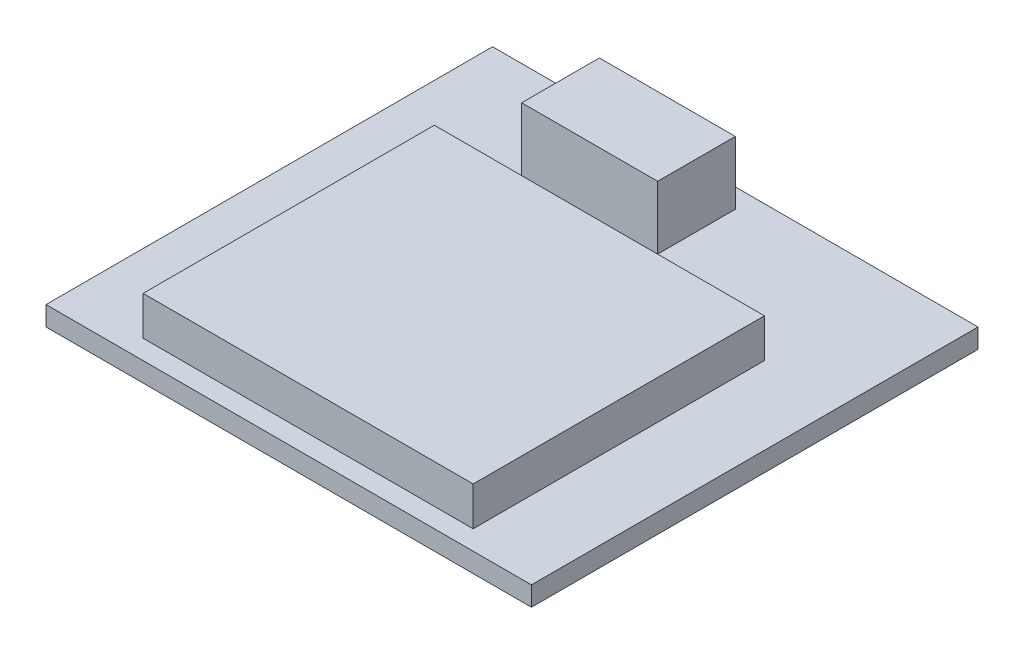
from build123d import *

# Parameters (mm, degrees)
SKETCH1_W           = 25
SKETCH1_H           = 23
BOSS_EXTRUDE1_DEPTH = 1
SKETCH2_W           = 17
SKETCH2_H           = 15
BOSS_EXTRUDE2_DEPTH = 2
SKETCH3_W           = 7
SKETCH3_H           = 4
BOSS_EXTRUDE3_DEPTH = 3.25
SKETCH4_W           = 15
SKETCH4_H           = 17
BOSS_EXTRUDE4_DEPTH = 0.75
SKETCH5_W           = 12.45
SKETCH5_H           = 0.6
CUT_EXTRUDE1_DEPTH  = 16.75
SKETCH6_R           = 0.770478249
CUT_EXTRUDE2_DEPTH  = 0.5


with BuildPart() as part:
    # Sketch1 → Boss-Extrude1 (new body)
    with BuildSketch(Plane(origin=(0, 0, 0), x_dir=(1, 0, 0), z_dir=(0, 1, 0))):
        Rectangle(SKETCH1_W, SKETCH1_H)
    extrude(amount=BOSS_EXTRUDE1_DEPTH)

    # Sketch2 → Boss-Extrude2 (add)
    with BuildSketch(Plane(origin=(0, 1, 0), x_dir=(1, 0, 0), z_dir=(0, 1, 0))):
        with Locations((0, -3)):
            Rectangle(SKETCH2_W, SKETCH2_H)
    extrude(amount=BOSS_EXTRUDE2_DEPTH)

    # Sketch3 → Boss-Extrude3 (add)
    with BuildSketch(Plane(origin=(0, 1, 0), x_dir=(1, 0, 0), z_dir=(0, 1, 0))):
        with Locations((-2.5, 8.5)):
            Rectangle(SKETCH3_W, SKETCH3_H)
    extrude(amount=BOSS_EXTRUDE3_DEPTH)


with BuildPart() as body_2:
    # Sketch4 → Boss-Extrude4 (new body)
    with BuildSketch(Plane.XZ):
        with Locations((0, -3)):
            Rectangle(SKETCH4_W, SKETCH4_H)
    extrude(amount=BOSS_EXTRUDE4_DEPTH)

    # Sketch5 → Cut-Extrude1 (cut)
    with BuildSketch(Plane(origin=(0, 0, -11.5), x_dir=(-1, 0, 0), z_dir=(0, 0, -1))):
        with Locations((1.225, -0.4)):
            Rectangle(SKETCH5_W, SKETCH5_H)
    extrude(amount=-CUT_EXTRUDE1_DEPTH, mode=Mode.SUBTRACT)

    # Sketch6 → Cut-Extrude2 (cut)
    with BuildSketch(Plane.XZ.offset(0.75)):
        with Locations((-5.547443391, 3.143551255)):
            Circle(SKETCH6_R)
        with Locations((-2.547443391, 3.143551255)):
            Circle(SKETCH6_R)
        with Locations((0.452556609, 3.143551255)):
            Circle(SKETCH6_R)
        with Locations((3.452556609, 3.143551255)):
            Circle(SKETCH6_R)
        with Locations((-2.547443391, -6.856448745)):
            Circle(SKETCH6_R)
        with Locations((0.452556609, -6.856448745)):
            Circle(SKETCH6_R)
        with Locations((3.452556609, -6.856448745)):
            Circle(SKETCH6_R)
        with Locations((-5.547443391, -6.856448745)):
            Circle(SKETCH6_R)
    extrude(amount=-CUT_EXTRUDE2_DEPTH, mode=Mode.SUBTRACT)


solid = Compound([part.part, body_2.part])
